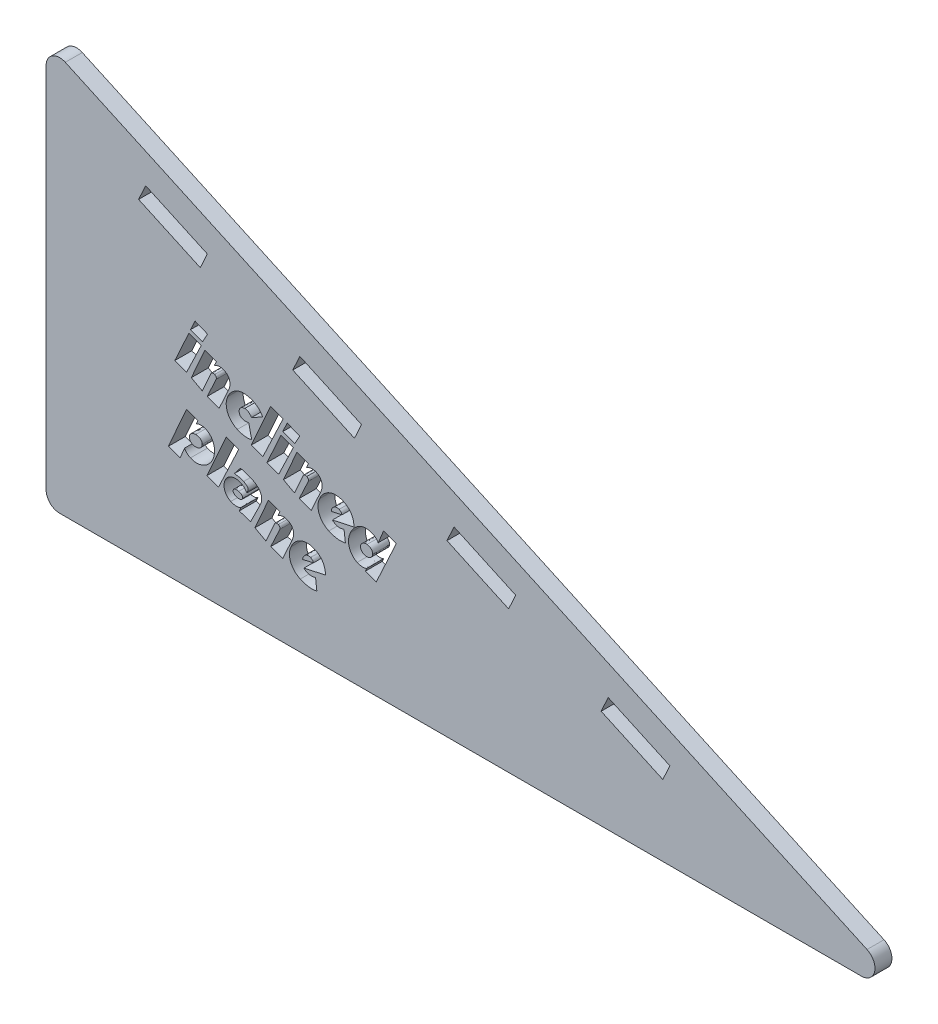
from build123d import *

# Parameters (mm, degrees)
EXTRUDE1_DEPTH     = 3.175
CUT_EXTRUDE1_DEPTH = 4.175
CUT_EXTRUDE3_DEPTH = 4.175


with BuildPart() as part:
    # Sketch1 → Extrude1 (new body)
    with BuildSketch(Plane.XY):
        with BuildLine():
            Line((0, 71.331666667), (0, 2.54))
            ThreePointArc((0, 2.54), (0.743948776, 0.743948776), (2.54, 0))
            Line((2.54, 0), (152.625697511, 0))
            ThreePointArc((152.625697511, 0), (155.107278383, 1.998376171), (153.684030844, 4.849010731))
            Line((153.684030844, 4.849010731), (3.598333333, 73.640677398))
            ThreePointArc((3.598333333, 73.640677398), (1.168243219, 73.469395212), (0, 71.331666667))
        make_face()
    extrude(amount=EXTRUDE1_DEPTH)

    # Sketch2 → Cut-Extrude1 (cut, through all)
    with BuildSketch(Plane.XY.offset(3.175)):
        Polygon((17.317580482, 58.271655465), (18.640497149, 61.157918879), (30.185550803, 55.866252212), (28.862634137, 52.979988799), align=None)
        Polygon((46.180214619, 45.042488799), (47.503131285, 47.928752212), (59.04818494, 42.637085546), (57.725268273, 39.750822132), align=None)
        Polygon((75.042848755, 31.813322132), (76.365765422, 34.699585546), (87.910819077, 29.407918879), (86.58790241, 26.521655465), align=None)
        Polygon((116.773453213, 16.178752212), (105.228399559, 21.470418879), (103.905482892, 18.584155465), (115.450536547, 13.292488799), align=None)
    extrude(amount=-CUT_EXTRUDE1_DEPTH, mode=Mode.SUBTRACT)

    # Sketch5 → Cut-Extrude3 (cut, through all)
    with BuildSketch(Plane.XY.offset(3.175)):
        Polygon((24.096896601, 35.534277169), (26.299982656, 34.743589265), (29.051449032, 40.463323539), (26.738368087, 41.303429437), align=None)
        Polygon((27.042846695, 42.023975672), (29.296944873, 41.185463903), (30.223133729, 42.889587632), (27.88773498, 43.838094291), align=None)
        with BuildLine():
            Line((31.868168414, 39.243814977), (29.711312094, 40.024938108))
            Line((29.711312094, 40.024938108), (27.186212014, 34.300421448))
            Line((27.186212014, 34.300421448), (29.247420602, 33.174966487))
            Line((29.247420602, 33.174966487), (30.860678987, 36.801609596))
            add(Edge.make_bspline(
                [(30.860678987, 36.801609596), (30.876732098, 36.832877524), (30.90761091, 36.893022659), (30.977754715, 36.966042047), (31.062592261, 37.017697935), (31.158897773, 37.048626669), (31.259790989, 37.062246546), (31.361550086, 37.061262608), (31.461482499, 37.042168795), (31.524182654, 37.016815826), (31.555719161, 37.004063958)],
                knots=[0, 0, 0, 0, 0.000104995, 0.000201962, 0.000299295, 0.000400117, 0.000503145, 0.000603588, 0.000704258, 0.000806133, 0.000806133, 0.000806133, 0.000806133], degree=3))
            add(Edge.make_bspline(
                [(31.555719161, 37.004063958), (31.58772355, 36.987592248), (31.650041947, 36.955518817), (31.730937757, 36.890416468), (31.797752758, 36.813749544), (31.849708281, 36.727661944), (31.883628419, 36.636221783), (31.89623315, 36.542867323), (31.88341384, 36.450173301), (31.857433365, 36.393541198), (31.844256481, 36.364818294)],
                knots=[0, 0, 0, 0, 0.000107766, 0.00020984, 0.000309266, 0.000411514, 0.000509847, 0.000599813, 0.000691569, 0.000786, 0.000786, 0.000786, 0.000786], degree=3))
            Line((31.844256481, 36.364818294), (30.148103396, 32.739769314))
            Line((30.148103396, 32.739769314), (32.389448544, 31.929951864))
            Line((32.389448544, 31.929951864), (34.162119813, 35.798902556))
            add(Edge.make_bspline(
                [(34.162119813, 35.798902556), (34.191747509, 35.868141664), (34.250270762, 36.004908885), (34.320636525, 36.213520606), (34.371898013, 36.422091037), (34.405453902, 36.628960067), (34.421497765, 36.833174358), (34.420610179, 37.032761783), (34.399896648, 37.227231969), (34.359483774, 37.415497261), (34.303275191, 37.597302752), (34.225524725, 37.770071654), (34.12833141, 37.932854746), (34.010373225, 38.08506831), (33.874695161, 38.22854187), (33.715769044, 38.357477924), (33.535552156, 38.472997978), (33.40505006, 38.537784173), (33.337955203, 38.571092607)],
                knots=[0, 0, 0, 0, 0.000225877, 0.000446173, 0.000659596, 0.000869519, 0.001074189, 0.001273462, 0.001467462, 0.001659744, 0.001850321, 0.002037269, 0.00222673, 0.002417719, 0.002613907, 0.002817819, 0.003030071, 0.003254668, 0.003254668, 0.003254668, 0.003254668], degree=3))
            add(Edge.make_bspline(
                [(33.337955203, 38.571092607), (33.270020817, 38.600418375), (33.136671001, 38.657982533), (32.927904429, 38.71444242), (32.719253564, 38.75074894), (32.506096943, 38.760588225), (32.285038304, 38.742038677), (32.052190468, 38.68287011), (31.805095633, 38.588550027), (31.641446645, 38.501773299), (31.555719161, 38.456315331)],
                knots=[0, 0, 0, 0, 0.000221721, 0.000435222, 0.000646977, 0.000856027, 0.001073671, 0.001309908, 0.001574294, 0.001865164, 0.001865164, 0.001865164, 0.001865164], degree=3))
            Line((31.555719161, 38.456315331), (31.51586594, 38.473850748))
            Line((31.51586594, 38.473850748), (31.868168414, 39.243814977))
        make_face()
        with BuildLine():
            Line((38.483017299, 29.923475032), (37.947390009, 32.344956739))
            Line((37.947390009, 32.344956739), (37.319303246, 32.317856548))
            add(Edge.make_bspline(
                [(37.319303246, 32.317856548), (37.238805912, 32.318761735), (37.083736337, 32.320505482), (36.862363063, 32.368621723), (36.661771148, 32.446695739), (36.513934706, 32.541529796), (36.411000461, 32.633805945), (36.342294121, 32.709690897), (36.284678226, 32.793693984), (36.236139917, 32.883863752), (36.197880086, 32.981865022), (36.169613273, 33.087212728), (36.14996998, 33.199813762), (36.14525939, 33.277441817), (36.142836163, 33.31737533)],
                knots=[0, 0, 0, 0, 0.000240972, 0.000464207, 0.000675271, 0.00088398, 0.000986712, 0.001089444, 0.001190265, 0.001291539, 0.001396037, 0.001505092, 0.001618309, 0.001738251, 0.001738251, 0.001738251, 0.001738251], degree=3))
            add(Edge.make_bspline(
                [(36.142836163, 33.31737533), (36.141993955, 33.35566017), (36.140352126, 33.430293991), (36.152083049, 33.539850507), (36.17367686, 33.643298763), (36.218657595, 33.770913781), (36.299405592, 33.915172994), (36.434649723, 34.058605231), (36.597661869, 34.171365833), (36.784157941, 34.258083331), (36.991830969, 34.317973612), (37.138771041, 34.33201465), (37.214090743, 34.339211916)],
                knots=[0, 0, 0, 0, 0.000114777, 0.000223751, 0.000329745, 0.000431082, 0.000628812, 0.000820559, 0.001017368, 0.001219897, 0.001435364, 0.001661961, 0.001661961, 0.001661961, 0.001661961], degree=3))
            add(Edge.make_bspline(
                [(37.214090743, 34.339211916), (37.263879742, 34.337772035), (37.372779826, 34.334622681), (37.538841864, 34.277115273), (37.714443311, 34.197767756), (37.890307845, 34.092024772), (38.061197095, 33.966760838), (38.217574511, 33.821897025), (38.357492881, 33.665603581), (38.425858114, 33.547148229), (38.459105366, 33.489541245)],
                knots=[0, 0, 0, 0, 0.000148673, 0.000325183, 0.000521365, 0.00072723, 0.000939255, 0.001155869, 0.001366124, 0.00156518, 0.00156518, 0.00156518, 0.00156518], degree=3))
            Line((38.459105366, 33.489541245), (40.571326078, 34.614996205))
            add(Edge.make_bspline(
                [(40.571326078, 34.614996205), (40.526915764, 34.684587904), (40.43503867, 34.828560837), (40.276762461, 35.042605235), (40.097926883, 35.26480977), (39.90119603, 35.496742278), (39.675028365, 35.72539605), (39.407011631, 35.93146549), (39.105804094, 36.123779986), (38.885432413, 36.230496907), (38.771554618, 36.285643228)],
                knots=[0, 0, 0, 0, 0.000247604, 0.000512248, 0.000798056, 0.001103239, 0.001424498, 0.001760614, 0.002115303, 0.002494585, 0.002494585, 0.002494585, 0.002494585], degree=3))
            add(Edge.make_bspline(
                [(38.771554618, 36.285643228), (38.65442819, 36.336718724), (38.423235347, 36.43753533), (38.066503133, 36.548894379), (37.711329037, 36.632231277), (37.357342722, 36.679283593), (37.008442185, 36.696274619), (36.667144105, 36.67893885), (36.335399787, 36.627808328), (36.014014682, 36.543524793), (35.705377567, 36.424752052), (35.409183358, 36.27410567), (35.128128407, 36.087709536), (34.861151067, 35.869208693), (34.613536102, 35.616454684), (34.388580826, 35.330574101), (34.183509642, 35.013926201), (34.071784465, 34.783695055), (34.014674163, 34.666008328)],
                knots=[0, 0, 0, 0, 0.000383082, 0.000756156, 0.001119271, 0.001476384, 0.001825862, 0.002165864, 0.002499769, 0.00283114, 0.003160647, 0.003490027, 0.003826052, 0.004170391, 0.004523227, 0.00488522, 0.005260207, 0.005652327, 0.005652327, 0.005652327, 0.005652327], degree=3))
            add(Edge.make_bspline(
                [(34.014674163, 34.666008328), (33.969655101, 34.561709328), (33.880592004, 34.355370247), (33.792040152, 34.032884037), (33.732644536, 33.708609056), (33.711027568, 33.382424811), (33.722751181, 33.058439886), (33.763546498, 32.739452352), (33.837798709, 32.427841206), (33.941059252, 32.123446915), (34.07736921, 31.831099078), (34.240409048, 31.549433384), (34.435152454, 31.283551677), (34.654137128, 31.02898766), (34.903443847, 30.794887901), (35.179172621, 30.582479668), (35.480021989, 30.390456643), (35.6964103, 30.284855378), (35.806474978, 30.231141898)],
                knots=[0, 0, 0, 0, 0.000340428, 0.000673482, 0.00100057, 0.001328128, 0.001651928, 0.001971856, 0.002291243, 0.002611362, 0.002934467, 0.003257368, 0.003586122, 0.003921742, 0.00426344, 0.004610041, 0.00496473, 0.005331899, 0.005331899, 0.005331899, 0.005331899], degree=3))
            add(Edge.make_bspline(
                [(35.806474978, 30.231141898), (35.905895815, 30.187457688), (36.107672457, 30.09879968), (36.423023452, 29.986208398), (36.750296669, 29.892650725), (37.088704842, 29.830437629), (37.433367353, 29.799136532), (37.783465998, 29.795994251), (38.137222304, 29.831510448), (38.367274166, 29.89269301), (38.483017299, 29.923475032)],
                knots=[0, 0, 0, 0, 0.000325702, 0.000661019, 0.001003712, 0.001345771, 0.001691576, 0.002040693, 0.002395067, 0.002753888, 0.002753888, 0.002753888, 0.002753888], degree=3))
        make_face()
        Polygon((38.398924584, 28.97975076), (40.582881093, 28.1970335), (44.357778184, 36.204342658), (42.016002919, 37.058795715), align=None)
        Polygon((41.347670038, 27.627398128), (43.550756093, 26.836710224), (46.302222469, 32.556444498), (43.989141524, 33.396550396), align=None)
        Polygon((44.293620132, 34.117096631), (46.54771831, 33.278584862), (47.473907165, 34.982708591), (45.138508416, 35.93121525), align=None)
        with BuildLine():
            Line((49.11894185, 31.336935936), (46.962085531, 32.118059067))
            Line((46.962085531, 32.118059067), (44.43698545, 26.393542407))
            Line((44.43698545, 26.393542407), (46.498194039, 25.268087446))
            Line((46.498194039, 25.268087446), (48.111452424, 28.894730555))
            add(Edge.make_bspline(
                [(48.111452424, 28.894730555), (48.127505534, 28.925998483), (48.158384347, 28.986143618), (48.228528151, 29.059163006), (48.313365697, 29.110818894), (48.409671209, 29.141747628), (48.510564425, 29.155367505), (48.612323523, 29.154383568), (48.712255936, 29.135289754), (48.774956091, 29.109936785), (48.806492598, 29.097184918)],
                knots=[0, 0, 0, 0, 0.000104995, 0.000201962, 0.000299295, 0.000400117, 0.000503145, 0.000603588, 0.000704258, 0.000806133, 0.000806133, 0.000806133, 0.000806133], degree=3))
            add(Edge.make_bspline(
                [(48.806492598, 29.097184918), (48.838496986, 29.080713207), (48.900815383, 29.048639776), (48.981711193, 28.983537427), (49.048526195, 28.906870503), (49.100481717, 28.820782903), (49.134401855, 28.729342742), (49.147006586, 28.635988282), (49.134187277, 28.54329426), (49.108206802, 28.486662157), (49.095029918, 28.457939253)],
                knots=[0, 0, 0, 0, 0.000107766, 0.00020984, 0.000309266, 0.000411514, 0.000509847, 0.000599813, 0.000691569, 0.000786, 0.000786, 0.000786, 0.000786], degree=3))
            Line((49.095029918, 28.457939253), (47.398876833, 24.832890273))
            Line((47.398876833, 24.832890273), (49.64022198, 24.023072823))
            Line((49.64022198, 24.023072823), (51.412893249, 27.892023515))
            add(Edge.make_bspline(
                [(51.412893249, 27.892023515), (51.442520946, 27.961262623), (51.501044198, 28.098029844), (51.571409962, 28.306641565), (51.622671449, 28.515211996), (51.656227339, 28.722081026), (51.672271201, 28.926295317), (51.671383616, 29.125882742), (51.650670084, 29.320352928), (51.61025721, 29.50861822), (51.554048627, 29.690423711), (51.476298161, 29.863192613), (51.379104847, 30.025975705), (51.261146662, 30.178189269), (51.125468598, 30.321662829), (50.966542481, 30.450598883), (50.786325592, 30.566118937), (50.655823496, 30.630905132), (50.58872864, 30.664213566)],
                knots=[0, 0, 0, 0, 0.000225877, 0.000446173, 0.000659596, 0.000869519, 0.001074189, 0.001273462, 0.001467462, 0.001659744, 0.001850321, 0.002037269, 0.00222673, 0.002417719, 0.002613907, 0.002817819, 0.003030071, 0.003254668, 0.003254668, 0.003254668, 0.003254668], degree=3))
            add(Edge.make_bspline(
                [(50.58872864, 30.664213566), (50.520794253, 30.693539334), (50.387444438, 30.751103492), (50.178677866, 30.807563379), (49.970027, 30.843869899), (49.75687038, 30.853709184), (49.53581174, 30.835159636), (49.302963904, 30.775991069), (49.05586907, 30.681670986), (48.892220081, 30.594894258), (48.806492598, 30.54943629)],
                knots=[0, 0, 0, 0, 0.000221721, 0.000435222, 0.000646977, 0.000856027, 0.001073671, 0.001309908, 0.001574294, 0.001865164, 0.001865164, 0.001865164, 0.001865164], degree=3))
            Line((48.806492598, 30.54943629), (48.766639377, 30.566971707))
            Line((48.766639377, 30.566971707), (49.11894185, 31.336935936))
        make_face()
        with BuildLine():
            Line((56.027110442, 21.917760003), (55.783208729, 23.999692267))
            add(Edge.make_bspline(
                [(55.783208729, 23.999692267), (55.66001763, 23.967667303), (55.412038033, 23.903202111), (55.090232244, 23.864867995), (54.824509394, 23.869294399), (54.614920169, 23.902345821), (54.396842016, 23.965413961), (54.25277509, 24.026786942), (54.177920988, 24.058675034)],
                knots=[0, 0, 0, 0, 0.00038164, 0.000768228, 0.000967552, 0.001177227, 0.001402767, 0.001646689, 0.001646689, 0.001646689, 0.001646689], degree=3))
            add(Edge.make_bspline(
                [(54.177920988, 24.058675034), (54.126068992, 24.083631222), (54.016930287, 24.136159306), (53.859307371, 24.225950811), (53.712195631, 24.321892697), (53.638803433, 24.405202456), (53.605628735, 24.442860084)],
                knots=[0, 0, 0, 0, 0.000172527, 0.000363137, 0.000544931, 0.000694889, 0.000694889, 0.000694889, 0.000694889], degree=3))
            Line((53.605628735, 24.442860084), (57.624427538, 25.322819203))
            add(Edge.make_bspline(
                [(57.624427538, 25.322819203), (57.625058662, 25.406805839), (57.626306488, 25.572859785), (57.607877131, 25.819441053), (57.574947682, 26.060865204), (57.524190546, 26.297103786), (57.454320686, 26.527079366), (57.372014267, 26.753027221), (57.271522379, 26.973308756), (57.152812288, 27.186026218), (57.022140933, 27.392739946), (56.870718342, 27.58523302), (56.706703523, 27.767431229), (56.527355659, 27.937992283), (56.330209862, 28.093282242), (56.119525574, 28.239274687), (55.892240515, 28.372068269), (55.732215606, 28.449440812), (55.650896036, 28.488759077)],
                knots=[0, 0, 0, 0, 0.000251877, 0.000497999, 0.000741029, 0.000982412, 0.001221982, 0.001461553, 0.001703383, 0.001947404, 0.002191936, 0.002436191, 0.002681112, 0.002926939, 0.003177643, 0.003433226, 0.003695425, 0.003966333, 0.003966333, 0.003966333, 0.003966333], degree=3))
            add(Edge.make_bspline(
                [(55.650896036, 28.488759077), (55.548028112, 28.532732795), (55.344005269, 28.61994796), (55.027575759, 28.714592292), (54.70853575, 28.779561758), (54.388039391, 28.810746573), (54.068848277, 28.81295369), (53.75337809, 28.783318915), (53.444566672, 28.718009687), (53.141509204, 28.624670835), (52.848642918, 28.496330267), (52.564447893, 28.337015867), (52.293150236, 28.143339914), (52.031607983, 27.919873773), (51.787344063, 27.661997028), (51.56158652, 27.370594605), (51.358700452, 27.044091494), (51.244250809, 26.809114172), (51.185741158, 26.688987618)],
                knots=[0, 0, 0, 0, 0.000335397, 0.000665208, 0.000988785, 0.001310787, 0.001629617, 0.001945117, 0.002259322, 0.002574952, 0.002894796, 0.003216704, 0.003550642, 0.003893172, 0.004247234, 0.004614247, 0.00499732, 0.005397989, 0.005397989, 0.005397989, 0.005397989], degree=3))
            add(Edge.make_bspline(
                [(51.185741158, 26.688987618), (51.143284095, 26.588797577), (51.059132664, 26.3902173), (50.96994232, 26.080098304), (50.914319102, 25.765335911), (50.890254206, 25.447561858), (50.898354601, 25.130905758), (50.93696123, 24.819270876), (51.003761426, 24.513479264), (51.102921818, 24.216254601), (51.231088616, 23.928020084), (51.387884407, 23.65041886), (51.576160088, 23.386135284), (51.788388475, 23.13188565), (52.031593797, 22.896736054), (52.304267491, 22.684852444), (52.603238422, 22.493174703), (52.818590187, 22.387550822), (52.928123979, 22.33382763)],
                knots=[0, 0, 0, 0, 0.000326217, 0.000646573, 0.000965534, 0.001283666, 0.001600998, 0.001914198, 0.002224395, 0.002538454, 0.002852461, 0.00316942, 0.00349317, 0.003824645, 0.004161731, 0.004505815, 0.004859159, 0.005224909, 0.005224909, 0.005224909, 0.005224909], degree=3))
            add(Edge.make_bspline(
                [(52.928123979, 22.33382763), (53.063950347, 22.274607224), (53.327669742, 22.159625354), (53.725062757, 22.021932146), (54.109140763, 21.91906409), (54.4849101, 21.850218537), (54.859474679, 21.816076984), (55.240746747, 21.817475033), (55.632252251, 21.848240689), (55.894033344, 21.894330254), (56.027110442, 21.917760003)],
                knots=[0, 0, 0, 0, 0.000444396, 0.000862836, 0.001260337, 0.001636186, 0.002007536, 0.002386939, 0.0027788, 0.003183975, 0.003183975, 0.003183975, 0.003183975], degree=3))
        make_face()
        with BuildLine():
            Line((55.389458906, 26.177272261), (53.382450698, 25.730916186))
            add(Edge.make_bspline(
                [(53.382450698, 25.730916186), (53.38210492, 25.762260971), (53.381430111, 25.823432538), (53.385604487, 25.901472441), (53.398193596, 25.968265013), (53.418680536, 26.028505341), (53.445722497, 26.101066809), (53.468731388, 26.152431995), (53.481286686, 26.180460519)],
                knots=[0, 0, 0, 0, 9.4054e-05, 0.000183552, 0.000233887, 0.000297413, 0.000374097, 0.000466198, 0.000466198, 0.000466198, 0.000466198], degree=3))
            add(Edge.make_bspline(
                [(53.481286686, 26.180460519), (53.51318422, 26.241840167), (53.576845669, 26.364342344), (53.71047407, 26.524547848), (53.867744698, 26.659923699), (54.045437169, 26.765940039), (54.237448468, 26.837861197), (54.406132378, 26.861527671), (54.541392517, 26.860417124), (54.642768598, 26.844867833), (54.744630359, 26.820532353), (54.809539085, 26.792545262), (54.842672714, 26.778258833)],
                knots=[0, 0, 0, 0, 0.000207022, 0.000413177, 0.000621185, 0.00082705, 0.001030799, 0.001232121, 0.001334157, 0.001435607, 0.001539225, 0.001647274, 0.001647274, 0.001647274, 0.001647274], degree=3))
            add(Edge.make_bspline(
                [(54.842672714, 26.778258833), (54.908437727, 26.745632144), (55.033893839, 26.683392097), (55.168687588, 26.573852086), (55.257263927, 26.474345268), (55.310871337, 26.386362122), (55.358392079, 26.287546288), (55.378866123, 26.214872137), (55.389458906, 26.177272261)],
                knots=[0, 0, 0, 0, 0.000219718, 0.000419144, 0.00051632, 0.000618045, 0.000727158, 0.000844129, 0.000844129, 0.000844129, 0.000844129], degree=3))
        make_face(mode=Mode.SUBTRACT)
        with BuildLine():
            Line((65.55864186, 26.586431996), (63.175419245, 27.458420471))
            Line((63.175419245, 27.458420471), (62.177494592, 25.038532894))
            add(Edge.make_bspline(
                [(62.177494592, 25.038532894), (62.152559917, 25.088568721), (62.102690567, 25.188640376), (62.007681895, 25.328148009), (61.894913847, 25.456171358), (61.767150229, 25.573308878), (61.628713418, 25.680754596), (61.482385575, 25.780421641), (61.329004866, 25.871556771), (61.22091011, 25.923024685), (61.166816908, 25.948780461)],
                knots=[0, 0, 0, 0, 0.000167573, 0.000335146, 0.000504605, 0.000678328, 0.000854355, 0.00102989, 0.001209242, 0.001388898, 0.001388898, 0.001388898, 0.001388898], degree=3))
            add(Edge.make_bspline(
                [(61.166816908, 25.948780461), (61.058259867, 25.995318021), (60.846507413, 26.086094652), (60.519980312, 26.178717793), (60.197988186, 26.232233529), (59.881202562, 26.246412411), (59.572311087, 26.2253626), (59.272431381, 26.172717856), (58.982400937, 26.088223424), (58.704295378, 25.97027843), (58.436999524, 25.825684914), (58.184777676, 25.649412376), (57.94268457, 25.450037169), (57.715972943, 25.223346777), (57.503449302, 24.975013975), (57.310768116, 24.703791217), (57.133607396, 24.413706621), (57.034180307, 24.207312839), (56.983822835, 24.102779265)],
                knots=[0, 0, 0, 0, 0.000354044, 0.000690601, 0.001015311, 0.001331274, 0.001639638, 0.001942347, 0.002242999, 0.0025438, 0.002846978, 0.003152972, 0.003465462, 0.003786721, 0.004113518, 0.004444859, 0.004783865, 0.005131769, 0.005131769, 0.005131769, 0.005131769], degree=3))
            add(Edge.make_bspline(
                [(56.983822835, 24.102779265), (56.933364903, 23.986163925), (56.835098841, 23.759057308), (56.725830126, 23.41155725), (56.653962683, 23.070320012), (56.616301208, 22.735984788), (56.614658046, 22.412053257), (56.636578032, 22.099562049), (56.691764687, 21.800736959), (56.772389447, 21.515736173), (56.881745907, 21.247040964), (57.014608216, 20.994250399), (57.169858936, 20.756721409), (57.348038866, 20.536950412), (57.546983352, 20.338480734), (57.762476007, 20.161629806), (57.993211157, 20.006496211), (58.159775932, 19.925349328), (58.243184618, 19.884714358)],
                knots=[0, 0, 0, 0, 0.000381, 0.000741992, 0.001090596, 0.001425781, 0.001749404, 0.002061178, 0.002364167, 0.002659339, 0.00294826, 0.00323277, 0.003514859, 0.003798184, 0.004079989, 0.004356357, 0.004633576, 0.004911636, 0.004911636, 0.004911636, 0.004911636], degree=3))
            add(Edge.make_bspline(
                [(58.243184618, 19.884714358), (58.313873295, 19.854141841), (58.455568324, 19.792859414), (58.67851874, 19.724957882), (58.90852971, 19.676248899), (59.142207689, 19.643125294), (59.375684769, 19.635071157), (59.601219011, 19.660451125), (59.816501811, 19.717372398), (59.948171945, 19.781027736), (60.014261758, 19.81297856)],
                knots=[0, 0, 0, 0, 0.000230907, 0.000462851, 0.000697665, 0.00093574, 0.001170164, 0.001396379, 0.001614489, 0.001834294, 0.001834294, 0.001834294, 0.001834294], degree=3))
            Line((60.014261758, 19.81297856), (60.033391304, 19.803413787))
            Line((60.033391304, 19.803413787), (59.771954174, 19.232715662))
            Line((59.771954174, 19.232715662), (61.791715413, 18.465939691))
            Line((61.791715413, 18.465939691), (65.55864186, 26.586431996))
        make_face()
        with BuildLine():
            add(Edge.make_bspline(
                [(59.928178801, 21.714774265), (59.885043537, 21.719994418), (59.800924693, 21.730174332), (59.679151339, 21.755556172), (59.565358769, 21.790541383), (59.427106321, 21.849057834), (59.273683108, 21.943667476), (59.117434084, 22.082627346), (59.000375028, 22.246306697), (58.911097705, 22.420786088), (58.862493849, 22.610239089), (58.865155455, 22.739034261), (58.866488994, 22.803564262)],
                knots=[0, 0, 0, 0, 0.00013031, 0.000254119, 0.000372611, 0.0004869, 0.000703708, 0.000910238, 0.001109836, 0.00130375, 0.001495907, 0.001688856, 0.001688856, 0.001688856, 0.001688856], degree=3))
            add(Edge.make_bspline(
                [(58.866488994, 22.803564262), (58.875660795, 22.866356664), (58.894303354, 22.993988197), (58.970161588, 23.176462169), (59.080811438, 23.343544564), (59.227071299, 23.486414233), (59.404441302, 23.598032566), (59.571141627, 23.667954621), (59.716310468, 23.708485979), (59.834623716, 23.725267281), (59.95850771, 23.732485122), (60.042971066, 23.726450632), (60.085997556, 23.723376602)],
                knots=[0, 0, 0, 0, 0.000189782, 0.000385749, 0.000586919, 0.000787577, 0.000994083, 0.001211989, 0.001327616, 0.001445301, 0.001569806, 0.001699088, 0.001699088, 0.001699088, 0.001699088], degree=3))
            add(Edge.make_bspline(
                [(60.085997556, 23.723376602), (60.127548206, 23.718768808), (60.20910219, 23.709724812), (60.327329765, 23.684415251), (60.438611411, 23.64761676), (60.574091122, 23.583967082), (60.727948143, 23.489083153), (60.881128742, 23.346184648), (61.004423409, 23.184644299), (61.082856516, 23.003024827), (61.133874882, 22.815921688), (61.13244873, 22.689100137), (61.131746074, 22.62661596)],
                knots=[0, 0, 0, 0, 0.00012536, 0.000246051, 0.000361996, 0.000476118, 0.000694607, 0.000901039, 0.001101583, 0.001299216, 0.001491373, 0.001677995, 0.001677995, 0.001677995, 0.001677995], degree=3))
            add(Edge.make_bspline(
                [(61.131746074, 22.62661596), (61.12204089, 22.562243443), (61.102571221, 22.43310507), (61.027673316, 22.250104434), (60.915891487, 22.085732335), (60.771851395, 21.944141539), (60.595587542, 21.833686329), (60.430876828, 21.76619849), (60.287510242, 21.729813673), (60.17252793, 21.714924915), (60.052003327, 21.707535632), (59.970152767, 21.712320517), (59.928178801, 21.714774265)],
                knots=[0, 0, 0, 0, 0.000194777, 0.000390745, 0.000587056, 0.000787714, 0.000992017, 0.001207231, 0.001318968, 0.001434847, 0.001554576, 0.001680603, 0.001680603, 0.001680603, 0.001680603], degree=3))
        make_face(mode=Mode.SUBTRACT)
        with BuildLine():
            Line((26.295938899, 28.754297889), (22.894067957, 21.033931922))
            Line((22.894067957, 21.033931922), (25.085995111, 20.249620534))
            Line((25.085995111, 20.249620534), (25.935665782, 22.266193515))
            add(Edge.make_bspline(
                [(25.935665782, 22.266193515), (25.963963315, 22.202229229), (26.019606595, 22.076452094), (26.127248432, 21.902466592), (26.256079517, 21.747960605), (26.403371577, 21.614181387), (26.558986305, 21.495770435), (26.716775425, 21.391954442), (26.871517574, 21.29668613), (26.978279036, 21.245594713), (27.030832294, 21.220444997)],
                knots=[0, 0, 0, 0, 0.000209657, 0.000412262, 0.00061147, 0.000811144, 0.001007869, 0.001197543, 0.001377708, 0.001552373, 0.001552373, 0.001552373, 0.001552373], degree=3))
            add(Edge.make_bspline(
                [(27.030832294, 21.220444997), (27.131913968, 21.177400682), (27.330714413, 21.0927441), (27.642192157, 21.012857269), (27.95431296, 20.966686316), (28.26806629, 20.961027689), (28.577563341, 20.99087717), (28.881128544, 21.047664366), (29.175626041, 21.136381942), (29.46108677, 21.252922764), (29.736331038, 21.396528092), (29.997056359, 21.568088465), (30.246675516, 21.761933102), (30.479496509, 21.981104439), (30.693941301, 22.221909733), (30.88966634, 22.478770162), (31.061789541, 22.754132426), (31.156561047, 22.949156709), (31.204261594, 23.047316646)],
                knots=[0, 0, 0, 0, 0.000329179, 0.000647406, 0.00096145, 0.001273964, 0.001586141, 0.001892848, 0.002198991, 0.002507157, 0.002816616, 0.003128776, 0.00344224, 0.003763658, 0.004086547, 0.004408565, 0.004731481, 0.005058716, 0.005058716, 0.005058716, 0.005058716], degree=3))
            add(Edge.make_bspline(
                [(31.204261594, 23.047316646), (31.244886586, 23.141210044), (31.326187027, 23.32911346), (31.415395329, 23.624492311), (31.483362478, 23.927553656), (31.523515988, 24.238106576), (31.542183616, 24.549849797), (31.53221125, 24.858676211), (31.497064132, 25.161567923), (31.436823311, 25.458408008), (31.349843866, 25.747278049), (31.232804867, 26.024618765), (31.08628745, 26.289171451), (30.913358192, 26.540491526), (30.713350788, 26.774147801), (30.482813407, 26.981776147), (30.223447667, 27.161974172), (30.03333939, 27.257029208), (29.936929167, 27.305234775)],
                knots=[0, 0, 0, 0, 0.000306691, 0.000613762, 0.000923959, 0.001237565, 0.001552097, 0.001859913, 0.002163237, 0.00246587, 0.002767434, 0.003066766, 0.003367148, 0.003673142, 0.003980573, 0.004287583, 0.004601541, 0.004924587, 0.004924587, 0.004924587, 0.004924587], degree=3))
            add(Edge.make_bspline(
                [(29.936929167, 27.305234775), (29.858374219, 27.338798528), (29.706930793, 27.403504951), (29.476350631, 27.470427887), (29.254253577, 27.512615117), (29.035983103, 27.521489881), (28.818546052, 27.504494155), (28.596247609, 27.464441078), (28.366549046, 27.397933501), (28.214275367, 27.337874171), (28.13556358, 27.306828904)],
                knots=[0, 0, 0, 0, 0.00025606, 0.000493649, 0.000718789, 0.000932616, 0.001146823, 0.001371963, 0.001609108, 0.001862855, 0.001862855, 0.001862855, 0.001862855], degree=3))
            Line((28.13556358, 27.306828904), (28.446418703, 27.987521918))
            Line((28.446418703, 27.987521918), (26.295938899, 28.754297889))
        make_face()
        with BuildLine():
            add(Edge.make_bspline(
                [(28.035133463, 23.493672721), (27.989411816, 23.494051029), (27.900428931, 23.494787286), (27.770139565, 23.50729008), (27.647093611, 23.531649966), (27.494784517, 23.574421588), (27.323944698, 23.654727932), (27.141566218, 23.771809146), (26.998201118, 23.921995425), (26.889000033, 24.091023732), (26.818898315, 24.280301937), (26.809297066, 24.413444852), (26.804465999, 24.480438472)],
                knots=[0, 0, 0, 0, 0.000137132, 0.000266885, 0.00039194, 0.000513031, 0.000740612, 0.000955489, 0.001159543, 0.0013581, 0.001556267, 0.001756962, 0.001756962, 0.001756962, 0.001756962], degree=3))
            add(Edge.make_bspline(
                [(26.804465999, 24.480438472), (26.806793747, 24.547778935), (26.811393501, 24.680847242), (26.870865938, 24.873986241), (26.977035341, 25.049253132), (27.121456928, 25.206822003), (27.300599224, 25.341687335), (27.514982929, 25.436771549), (27.755868263, 25.499414625), (27.926841728, 25.507581058), (28.016003917, 25.511839831)],
                knots=[0, 0, 0, 0, 0.000201492, 0.000398158, 0.000598284, 0.000811569, 0.001036025, 0.001265718, 0.001510846, 0.001777999, 0.001777999, 0.001777999, 0.001777999], degree=3))
            add(Edge.make_bspline(
                [(28.016003917, 25.511839831), (28.102894355, 25.508746526), (28.269395261, 25.502819083), (28.506493793, 25.450251799), (28.716698586, 25.358688296), (28.894869096, 25.229578814), (29.042276005, 25.078886775), (29.148711348, 24.906849213), (29.216452356, 24.719114922), (29.224862527, 24.587280399), (29.229135963, 24.520291693)],
                knots=[0, 0, 0, 0, 0.000260434, 0.000499048, 0.000723871, 0.000943282, 0.001155248, 0.001352108, 0.001546206, 0.001746718, 0.001746718, 0.001746718, 0.001746718], degree=3))
            add(Edge.make_bspline(
                [(29.229135963, 24.520291693), (29.226858729, 24.45451155), (29.222357825, 24.324498529), (29.161637932, 24.13503922), (29.055938446, 23.960600988), (28.937310652, 23.828961955), (28.826158984, 23.732736801), (28.732052129, 23.67093309), (28.63339628, 23.615139953), (28.525881496, 23.573740702), (28.413392654, 23.537490404), (28.2932978, 23.511921799), (28.166152231, 23.498450106), (28.07926519, 23.495281912), (28.035133463, 23.493672721)],
                knots=[0, 0, 0, 0, 0.000196725, 0.000388822, 0.000588947, 0.000804603, 0.000917685, 0.001029103, 0.001141825, 0.001256978, 0.001373949, 0.001496199, 0.001624533, 0.001757, 0.001757, 0.001757, 0.001757], degree=3))
        make_face(mode=Mode.SUBTRACT)
        Polygon((30.092206974, 19.876594385), (32.276163483, 19.093877126), (36.051060574, 27.101186283), (33.709285309, 27.955639341), align=None)
        with BuildLine():
            Line((36.176603854, 17.210679591), (38.264912633, 16.459844907))
            Line((38.264912633, 16.459844907), (40.104537313, 20.188512262))
            add(Edge.make_bspline(
                [(40.104537313, 20.188512262), (40.147453553, 20.284952303), (40.230370987, 20.471281785), (40.31791336, 20.753810909), (40.363479511, 21.026335209), (40.371551757, 21.28742288), (40.346915009, 21.537170791), (40.296152365, 21.776457165), (40.217262122, 22.004995495), (40.111178659, 22.222072831), (39.981637964, 22.428196924), (39.828795874, 22.622637309), (39.652438079, 22.804564394), (39.455224387, 22.973406083), (39.242683127, 23.130490002), (39.021031017, 23.277183356), (38.78809905, 23.4084536), (38.627737423, 23.486011359), (38.547073437, 23.525023921)],
                knots=[0, 0, 0, 0, 0.000316498, 0.000611498, 0.000884578, 0.00114295, 0.001392781, 0.001635722, 0.001875187, 0.002116169, 0.00235899, 0.002604227, 0.002856765, 0.003117856, 0.003382165, 0.003649218, 0.003914769, 0.004183539, 0.004183539, 0.004183539, 0.004183539], degree=3))
            add(Edge.make_bspline(
                [(38.547073437, 23.525023921), (38.367772084, 23.604117584), (38.01185368, 23.761120806), (37.556438956, 23.92650803), (37.19254721, 24.043929075), (36.919493691, 24.113960716), (36.647893267, 24.177032623), (36.465349727, 24.205741017), (36.37427583, 24.220064095)],
                knots=[0, 0, 0, 0, 0.000587769, 0.001166738, 0.001452604, 0.001734481, 0.00201217, 0.002288659, 0.002288659, 0.002288659, 0.002288659], degree=3))
            Line((36.37427583, 24.220064095), (35.256791514, 22.807665944))
            add(Edge.make_bspline(
                [(35.256791514, 22.807665944), (35.40306835, 22.787389604), (35.692752634, 22.747234669), (36.052142821, 22.682742575), (36.336790182, 22.618519313), (36.550947927, 22.553460769), (36.768278804, 22.47646652), (36.910836398, 22.412781371), (36.983233046, 22.380439415)],
                knots=[0, 0, 0, 0, 0.000442999, 0.000877307, 0.00109501, 0.001317937, 0.001548381, 0.001786168, 0.001786168, 0.001786168, 0.001786168], degree=3))
            add(Edge.make_bspline(
                [(36.983233046, 22.380439415), (37.058966483, 22.34367425), (37.203307319, 22.273603288), (37.39760714, 22.149799499), (37.562468407, 22.01954776), (37.675817001, 21.900454676), (37.747208759, 21.799256156), (37.783857241, 21.717962305), (37.808701529, 21.632170063), (37.817894359, 21.54046504), (37.812112465, 21.44348697), (37.794581485, 21.341195518), (37.762307862, 21.233668387), (37.731145033, 21.162745091), (37.714938183, 21.125860019)],
                knots=[0, 0, 0, 0, 0.000252381, 0.000481015, 0.000689645, 0.000881392, 0.000972033, 0.001059768, 0.001147576, 0.001238943, 0.00133471, 0.00143823, 0.001549694, 0.00167048, 0.00167048, 0.00167048, 0.00167048], degree=3))
            Line((37.714938183, 21.125860019), (37.577843103, 20.826163797))
            add(Edge.make_bspline(
                [(37.577843103, 20.826163797), (37.552330493, 20.871637051), (37.499988863, 20.964929903), (37.409082279, 21.102788939), (37.300693036, 21.238748982), (37.182219722, 21.379656285), (37.041347158, 21.515611629), (36.875680103, 21.644058797), (36.683093253, 21.761798334), (36.54281557, 21.830063439), (36.46992356, 21.8655358)],
                knots=[0, 0, 0, 0, 0.000156403, 0.000320877, 0.000494666, 0.000677776, 0.000872814, 0.001080718, 0.001305462, 0.001548571, 0.001548571, 0.001548571, 0.001548571], degree=3))
            add(Edge.make_bspline(
                [(36.46992356, 21.8655358), (36.397079265, 21.896558421), (36.253535659, 21.957690165), (36.032146149, 22.026523885), (35.810619754, 22.072917916), (35.589503408, 22.097073236), (35.372453212, 22.099163355), (35.159684945, 22.086837559), (34.954084444, 22.048375017), (34.754033776, 21.995187687), (34.56255248, 21.921293678), (34.379207061, 21.829909454), (34.205512212, 21.719973537), (34.043061365, 21.591933016), (33.891296557, 21.448630617), (33.758227196, 21.284722767), (33.638155474, 21.105473631), (33.574070067, 20.97523268), (33.541508883, 20.909058497)],
                knots=[0, 0, 0, 0, 0.000237413, 0.000467835, 0.00069419, 0.000915475, 0.001133894, 0.001344808, 0.001553693, 0.001760199, 0.001965068, 0.002168249, 0.002373898, 0.002580545, 0.002788003, 0.002998645, 0.003212639, 0.003433671, 0.003433671, 0.003433671, 0.003433671], degree=3))
            add(Edge.make_bspline(
                [(33.541508883, 20.909058497), (33.508029036, 20.83154284), (33.442596967, 20.680048429), (33.3731574, 20.446766111), (33.3247985, 20.21652676), (33.307022232, 19.987982258), (33.309806071, 19.764894627), (33.333876333, 19.548726415), (33.37731635, 19.340134894), (33.438557158, 19.138669289), (33.522800466, 18.947237589), (33.622639185, 18.764187648), (33.743928655, 18.593376787), (33.879998441, 18.431719053), (34.034838236, 18.286418829), (34.202092291, 18.154441672), (34.381655252, 18.036815437), (34.511055929, 17.973972433), (34.5760985, 17.942384728)],
                knots=[0, 0, 0, 0, 0.000253105, 0.000494662, 0.000728825, 0.000957587, 0.001180788, 0.001397319, 0.001608979, 0.001819241, 0.002027724, 0.002235359, 0.00244366, 0.002655127, 0.002868246, 0.00307937, 0.003293827, 0.003510564, 0.003510564, 0.003510564, 0.003510564], degree=3))
            add(Edge.make_bspline(
                [(34.5760985, 17.942384728), (34.655744264, 17.907874026), (34.812553484, 17.839928215), (35.055085109, 17.766229394), (35.296285659, 17.711195044), (35.537231537, 17.677751962), (35.778487002, 17.673889935), (36.015245117, 17.712344233), (36.248534956, 17.783607163), (36.392894174, 17.860177027), (36.466735303, 17.899343249)],
                knots=[0, 0, 0, 0, 0.000260214, 0.000512319, 0.000759059, 0.001001874, 0.001240999, 0.001479762, 0.001718743, 0.001968986, 0.001968986, 0.001968986, 0.001968986], degree=3))
            Line((36.466735303, 17.899343249), (36.487458977, 17.889778476))
            Line((36.487458977, 17.889778476), (36.176603854, 17.210679591))
        make_face()
        with BuildLine():
            add(Edge.make_bspline(
                [(36.065014835, 20.322419084), (36.135280261, 20.301419959), (36.266632685, 20.262164721), (36.441930619, 20.179573242), (36.580837467, 20.080821525), (36.681718983, 19.967447097), (36.747935094, 19.849594152), (36.792751931, 19.736196959), (36.80527264, 19.623618455), (36.792041422, 19.553379571), (36.78556107, 19.518978149)],
                knots=[0, 0, 0, 0, 0.000219793, 0.000410876, 0.000578593, 0.000727659, 0.000861917, 0.00098245, 0.001091424, 0.001196031, 0.001196031, 0.001196031, 0.001196031], degree=3))
            add(Edge.make_bspline(
                [(36.78556107, 19.518978149), (36.773337357, 19.481263184), (36.748872132, 19.405778335), (36.672726204, 19.310006604), (36.571570909, 19.231422848), (36.44537637, 19.172367212), (36.297519575, 19.133253009), (36.130023873, 19.126213559), (35.945740453, 19.143524604), (35.820215474, 19.176449566), (35.754159712, 19.193775866)],
                knots=[0, 0, 0, 0, 0.000118116, 0.000236404, 0.000360142, 0.00049989, 0.000651458, 0.000815932, 0.001000093, 0.001204652, 0.001204652, 0.001204652, 0.001204652], degree=3))
            add(Edge.make_bspline(
                [(35.754159712, 19.193775866), (35.688764447, 19.214582676), (35.564425957, 19.254143451), (35.395868172, 19.333937208), (35.253894759, 19.426026085), (35.14308345, 19.533274015), (35.061670397, 19.648416379), (35.01122668, 19.768602819), (34.995495327, 19.893547838), (35.010212375, 19.973981704), (35.017672188, 20.014752218)],
                knots=[0, 0, 0, 0, 0.000205686, 0.000391078, 0.000557762, 0.00071108, 0.000850819, 0.00097811, 0.001098528, 0.001222306, 0.001222306, 0.001222306, 0.001222306], degree=3))
            add(Edge.make_bspline(
                [(35.017672188, 20.014752218), (35.033167435, 20.053090622), (35.063995371, 20.129365227), (35.148505014, 20.225632364), (35.262306433, 20.297381751), (35.400246524, 20.346539078), (35.554067439, 20.37555864), (35.718895651, 20.384220273), (35.891041313, 20.36550884), (36.005786281, 20.33708881), (36.065014835, 20.322419084)],
                knots=[0, 0, 0, 0, 0.000123367, 0.000245441, 0.000376761, 0.000523039, 0.000682172, 0.000844969, 0.001016439, 0.001199376, 0.001199376, 0.001199376, 0.001199376], degree=3))
        make_face(mode=Mode.SUBTRACT)
        with BuildLine():
            Line((43.78009924, 20.873456286), (41.623242921, 21.654579417))
            Line((41.623242921, 21.654579417), (39.09814284, 15.930062757))
            Line((39.09814284, 15.930062757), (41.159351429, 14.804607796))
            Line((41.159351429, 14.804607796), (42.772609814, 18.431250905))
            add(Edge.make_bspline(
                [(42.772609814, 18.431250905), (42.788662924, 18.462518833), (42.819541737, 18.522663968), (42.889685541, 18.595683355), (42.974523087, 18.647339244), (43.070828599, 18.678267978), (43.171721815, 18.691887855), (43.273480913, 18.690903917), (43.373413326, 18.671810104), (43.436113481, 18.646457135), (43.467649988, 18.633705267)],
                knots=[0, 0, 0, 0, 0.000104995, 0.000201962, 0.000299295, 0.000400117, 0.000503145, 0.000603588, 0.000704258, 0.000806133, 0.000806133, 0.000806133, 0.000806133], degree=3))
            add(Edge.make_bspline(
                [(43.467649988, 18.633705267), (43.499654376, 18.617233557), (43.561972773, 18.585160126), (43.642868583, 18.520057777), (43.709683585, 18.443390853), (43.761639107, 18.357303253), (43.795559245, 18.265863092), (43.808163976, 18.172508632), (43.795344667, 18.07981461), (43.769364192, 18.023182507), (43.756187308, 17.994459603)],
                knots=[0, 0, 0, 0, 0.000107766, 0.00020984, 0.000309266, 0.000411514, 0.000509847, 0.000599813, 0.000691569, 0.000786, 0.000786, 0.000786, 0.000786], degree=3))
            Line((43.756187308, 17.994459603), (42.060034223, 14.369410623))
            Line((42.060034223, 14.369410623), (44.30137937, 13.559593173))
            Line((44.30137937, 13.559593173), (46.074050639, 17.428543865))
            add(Edge.make_bspline(
                [(46.074050639, 17.428543865), (46.103678336, 17.497782972), (46.162201588, 17.634550194), (46.232567352, 17.843161915), (46.283828839, 18.051732346), (46.317384729, 18.258601376), (46.333428591, 18.462815667), (46.332541006, 18.662403092), (46.311827474, 18.856873278), (46.2714146, 19.04513857), (46.215206017, 19.226944061), (46.137455551, 19.399712963), (46.040262237, 19.562496055), (45.922304052, 19.714709619), (45.786625988, 19.858183179), (45.627699871, 19.987119233), (45.447482982, 20.102639286), (45.316980886, 20.167425482), (45.24988603, 20.200733916)],
                knots=[0, 0, 0, 0, 0.000225877, 0.000446173, 0.000659596, 0.000869519, 0.001074189, 0.001273462, 0.001467462, 0.001659744, 0.001850321, 0.002037269, 0.00222673, 0.002417719, 0.002613907, 0.002817819, 0.003030071, 0.003254668, 0.003254668, 0.003254668, 0.003254668], degree=3))
            add(Edge.make_bspline(
                [(45.24988603, 20.200733916), (45.181951643, 20.230059684), (45.048601828, 20.287623841), (44.839835256, 20.344083729), (44.63118439, 20.380390249), (44.41802777, 20.390229534), (44.19696913, 20.371679985), (43.964121294, 20.312511419), (43.71702646, 20.218191336), (43.553377471, 20.131414608), (43.467649988, 20.08595664)],
                knots=[0, 0, 0, 0, 0.000221721, 0.000435222, 0.000646977, 0.000856027, 0.001073671, 0.001309908, 0.001574294, 0.001865164, 0.001865164, 0.001865164, 0.001865164], degree=3))
            Line((43.467649988, 20.08595664), (43.427796767, 20.103492057))
            Line((43.427796767, 20.103492057), (43.78009924, 20.873456286))
        make_face()
        with BuildLine():
            Line((50.688267832, 11.454280353), (50.444366119, 13.536212617))
            add(Edge.make_bspline(
                [(50.444366119, 13.536212617), (50.32117502, 13.504187653), (50.073195423, 13.439722461), (49.751389634, 13.401388345), (49.485666784, 13.405814749), (49.276077559, 13.438866171), (49.057999405, 13.501934311), (48.91393248, 13.563307292), (48.839078378, 13.595195384)],
                knots=[0, 0, 0, 0, 0.00038164, 0.000768228, 0.000967552, 0.001177227, 0.001402767, 0.001646689, 0.001646689, 0.001646689, 0.001646689], degree=3))
            add(Edge.make_bspline(
                [(48.839078378, 13.595195384), (48.787226382, 13.620151572), (48.678087677, 13.672679655), (48.520464761, 13.762471161), (48.373353021, 13.858413047), (48.299960823, 13.941722806), (48.266786125, 13.979380434)],
                knots=[0, 0, 0, 0, 0.000172527, 0.000363137, 0.000544931, 0.000694889, 0.000694889, 0.000694889, 0.000694889], degree=3))
            Line((48.266786125, 13.979380434), (52.285584928, 14.859339553))
            add(Edge.make_bspline(
                [(52.285584928, 14.859339553), (52.286216052, 14.943326189), (52.287463878, 15.109380134), (52.269034521, 15.355961403), (52.236105072, 15.597385554), (52.185347936, 15.833624136), (52.115478076, 16.063599716), (52.033171657, 16.28954757), (51.932679768, 16.509829106), (51.813969678, 16.722546568), (51.683298323, 16.929260296), (51.531875732, 17.12175337), (51.367860913, 17.303951579), (51.188513049, 17.474512633), (50.991367252, 17.629802592), (50.780682964, 17.775795037), (50.553397905, 17.908588618), (50.393372996, 17.985961161), (50.312053426, 18.025279427)],
                knots=[0, 0, 0, 0, 0.000251877, 0.000497999, 0.000741029, 0.000982412, 0.001221982, 0.001461553, 0.001703383, 0.001947404, 0.002191936, 0.002436191, 0.002681112, 0.002926939, 0.003177643, 0.003433226, 0.003695425, 0.003966333, 0.003966333, 0.003966333, 0.003966333], degree=3))
            add(Edge.make_bspline(
                [(50.312053426, 18.025279427), (50.209185502, 18.069253145), (50.005162659, 18.15646831), (49.688733149, 18.251112642), (49.36969314, 18.316082108), (49.049196781, 18.347266923), (48.730005667, 18.34947404), (48.41453548, 18.319839265), (48.105724062, 18.254530037), (47.802666594, 18.161191184), (47.509800308, 18.032850617), (47.225605283, 17.873536217), (46.954307626, 17.679860263), (46.692765373, 17.456394123), (46.448501453, 17.198517378), (46.22274391, 16.907114955), (46.019857842, 16.580611843), (45.905408199, 16.345634522), (45.846898548, 16.225507968)],
                knots=[0, 0, 0, 0, 0.000335397, 0.000665208, 0.000988785, 0.001310787, 0.001629617, 0.001945117, 0.002259322, 0.002574952, 0.002894796, 0.003216704, 0.003550642, 0.003893172, 0.004247234, 0.004614247, 0.00499732, 0.005397989, 0.005397989, 0.005397989, 0.005397989], degree=3))
            add(Edge.make_bspline(
                [(45.846898548, 16.225507968), (45.804441485, 16.125317927), (45.720290054, 15.92673765), (45.63109971, 15.616618654), (45.575476492, 15.301856261), (45.551411596, 14.984082208), (45.559511991, 14.667426108), (45.59811862, 14.355791226), (45.664918816, 14.049999614), (45.764079208, 13.752774951), (45.892246006, 13.464540434), (46.049041797, 13.186939209), (46.237317478, 12.922655634), (46.449545865, 12.668406), (46.692751186, 12.433256404), (46.96542488, 12.221372794), (47.264395812, 12.029695053), (47.479747577, 11.924071172), (47.589281369, 11.87034798)],
                knots=[0, 0, 0, 0, 0.000326217, 0.000646573, 0.000965534, 0.001283666, 0.001600998, 0.001914198, 0.002224395, 0.002538454, 0.002852461, 0.00316942, 0.00349317, 0.003824645, 0.004161731, 0.004505815, 0.004859159, 0.005224909, 0.005224909, 0.005224909, 0.005224909], degree=3))
            add(Edge.make_bspline(
                [(47.589281369, 11.87034798), (47.725107737, 11.811127573), (47.988827132, 11.696145704), (48.386220147, 11.558452496), (48.770298153, 11.45558444), (49.14606749, 11.386738887), (49.520632069, 11.352597334), (49.901904137, 11.353995383), (50.293409641, 11.384761039), (50.555190734, 11.430850604), (50.688267832, 11.454280353)],
                knots=[0, 0, 0, 0, 0.000444396, 0.000862836, 0.001260337, 0.001636186, 0.002007536, 0.002386939, 0.0027788, 0.003183975, 0.003183975, 0.003183975, 0.003183975], degree=3))
        make_face()
        with BuildLine():
            Line((50.050616296, 15.713792611), (48.043608088, 15.267436536))
            add(Edge.make_bspline(
                [(48.043608088, 15.267436536), (48.04326231, 15.298781321), (48.042587501, 15.359952888), (48.046761877, 15.437992791), (48.059350986, 15.504785363), (48.079837926, 15.565025691), (48.106879887, 15.637587159), (48.129888778, 15.688952345), (48.142444076, 15.716980868)],
                knots=[0, 0, 0, 0, 9.4054e-05, 0.000183552, 0.000233887, 0.000297413, 0.000374097, 0.000466198, 0.000466198, 0.000466198, 0.000466198], degree=3))
            add(Edge.make_bspline(
                [(48.142444076, 15.716980868), (48.17434161, 15.778360517), (48.238003059, 15.900862693), (48.37163146, 16.061068198), (48.528902088, 16.196444049), (48.706594559, 16.302460389), (48.898605858, 16.374381547), (49.067289768, 16.398048021), (49.202549907, 16.396937474), (49.303925988, 16.381388183), (49.405787749, 16.357052702), (49.470696475, 16.329065612), (49.503830104, 16.314779183)],
                knots=[0, 0, 0, 0, 0.000207022, 0.000413177, 0.000621185, 0.00082705, 0.001030799, 0.001232121, 0.001334157, 0.001435607, 0.001539225, 0.001647274, 0.001647274, 0.001647274, 0.001647274], degree=3))
            add(Edge.make_bspline(
                [(49.503830104, 16.314779183), (49.569595117, 16.282152494), (49.695051229, 16.219912447), (49.829844978, 16.110372436), (49.918421317, 16.010865617), (49.972028727, 15.922882472), (50.019549469, 15.824066638), (50.040023513, 15.751392487), (50.050616296, 15.713792611)],
                knots=[0, 0, 0, 0, 0.000219718, 0.000419144, 0.00051632, 0.000618045, 0.000727158, 0.000844129, 0.000844129, 0.000844129, 0.000844129], degree=3))
        make_face(mode=Mode.SUBTRACT)
    extrude(amount=-CUT_EXTRUDE3_DEPTH, mode=Mode.SUBTRACT)


solid = part.part
